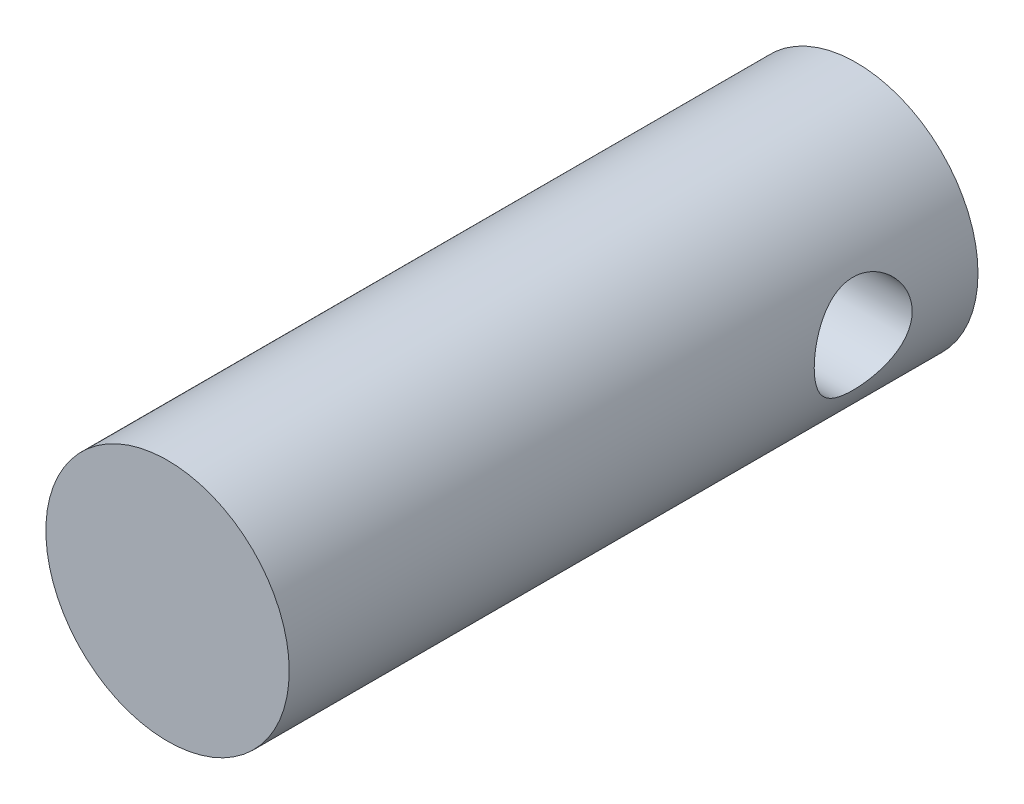
from build123d import *

# Parameters (mm, degrees)
SKETCH1_R                        = 15.9
BOSS_EXTRUDE1_DEPTH              = 90
F_12_8_12_8_DIAMETER_HOLE1_D     = 12.8
F_12_8_12_8_DIAMETER_HOLE1_DEPTH = 300
F_12_8_12_8_DIAMETER_HOLE1_TIP   = 3.845507962


with BuildPart() as part:
    # Sketch1 → Boss-Extrude1 (new body)
    with BuildSketch(Plane.XY):
        Circle(SKETCH1_R)
    extrude(amount=BOSS_EXTRUDE1_DEPTH)

    # Ø12.8 (12.8) Diameter Hole1
    with Locations(Plane(origin=(15.9, 0, 15), x_dir=(0, 0, 1), z_dir=(1, 0, 0))):
        with Locations((0, 0)):
            Hole(F_12_8_12_8_DIAMETER_HOLE1_D / 2, depth=F_12_8_12_8_DIAMETER_HOLE1_DEPTH)
            with Locations((0, 0, -(F_12_8_12_8_DIAMETER_HOLE1_DEPTH + F_12_8_12_8_DIAMETER_HOLE1_TIP / 2))):  # 118° drill point
                Cone(0, F_12_8_12_8_DIAMETER_HOLE1_D / 2, F_12_8_12_8_DIAMETER_HOLE1_TIP, mode=Mode.SUBTRACT)


solid = part.part
